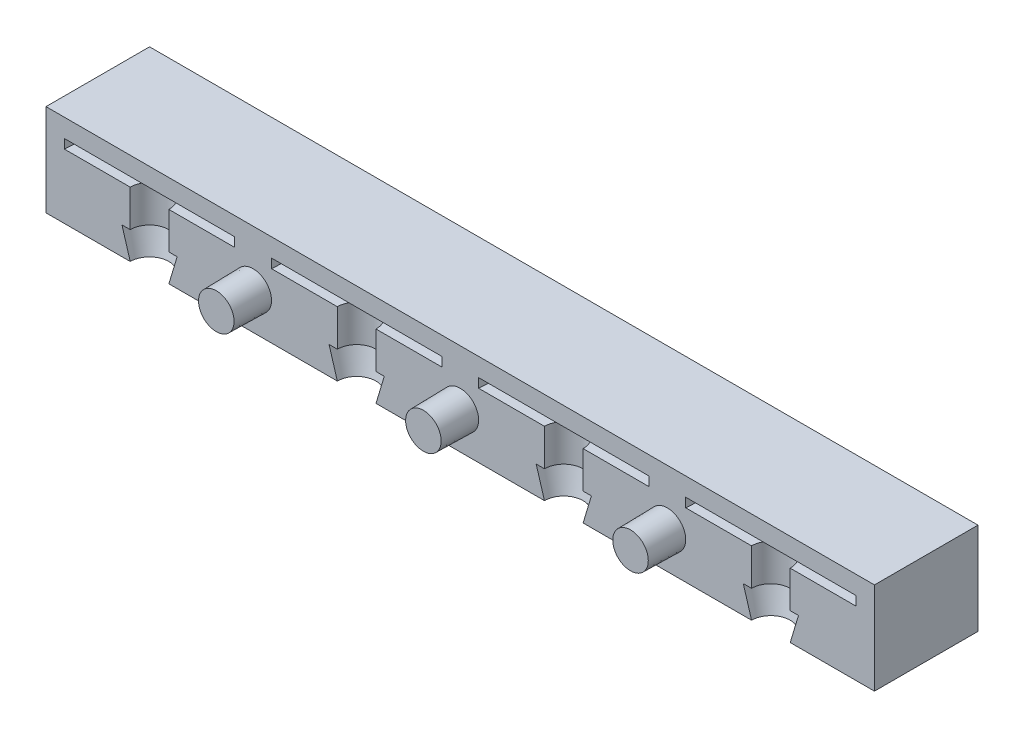
from build123d import *

# Parameters (mm, degrees)
SKETCH1_W           = 90
SKETCH1_H           = 11.25
BOSS_EXTRUDE1_DEPTH = 10
LPATTERN1_COUNT     = 4
LPATTERN1_PITCH     = 22.5
SKETCH3_R           = 2
BOSS_EXTRUDE2_DEPTH = 4
DRAFT1_ANGLE        = 1


with BuildPart() as part:
    # Sketch1 → Boss-Extrude1 (new body)
    with BuildSketch(Plane(origin=(0, 0, 0), x_dir=(1, 0, 0), z_dir=(0, 1, 0))):
        with Locations((0, 5.625)):
            Rectangle(SKETCH1_W, SKETCH1_H)
    extrude(amount=BOSS_EXTRUDE1_DEPTH)

    # Sketch2 → Cut-Revolve1 (revolve, cut)
    with BuildSketch(Plane.XY):
        Polygon((-33.75, 8), (-43, 8), (-43, 7), (-35.85, 7), (-35.85, 3), (-36.75, 3), (-35.85, 0), (-33.75, 0), align=None)
    cut_revolve1 = revolve(axis=Axis((-33.75, 16.960495744, 0), (0, -1, 0)), mode=Mode.SUBTRACT)

    # LPattern1: Cut-Revolve1 ×4
    with Locations(*[(i * LPATTERN1_PITCH, 0, 0) for i in range(1, LPATTERN1_COUNT)]):
        add(cut_revolve1, mode=Mode.SUBTRACT)

    # Sketch3 → Boss-Extrude2 (add)
    with BuildSketch(Plane.XY):
        with Locations((-22.5, 4)):
            Circle(SKETCH3_R)
        with Locations((0, 4)):
            Circle(SKETCH3_R)
        with Locations((22.5, 4)):
            Circle(SKETCH3_R)
    extrude(amount=BOSS_EXTRUDE2_DEPTH)

    # Draft1
    draft1_faces = [part.faces().sort_by_distance(p)[0] for p in [
        (20.5, 4, 2),
        (-2, 4, 2),
        (-24.5, 4, 2),
    ]]
    draft(draft1_faces, Plane(origin=(-45, 10, 0), x_dir=(1, 0, 0), z_dir=(0, 0, 1)), DRAFT1_ANGLE)


solid = part.part
